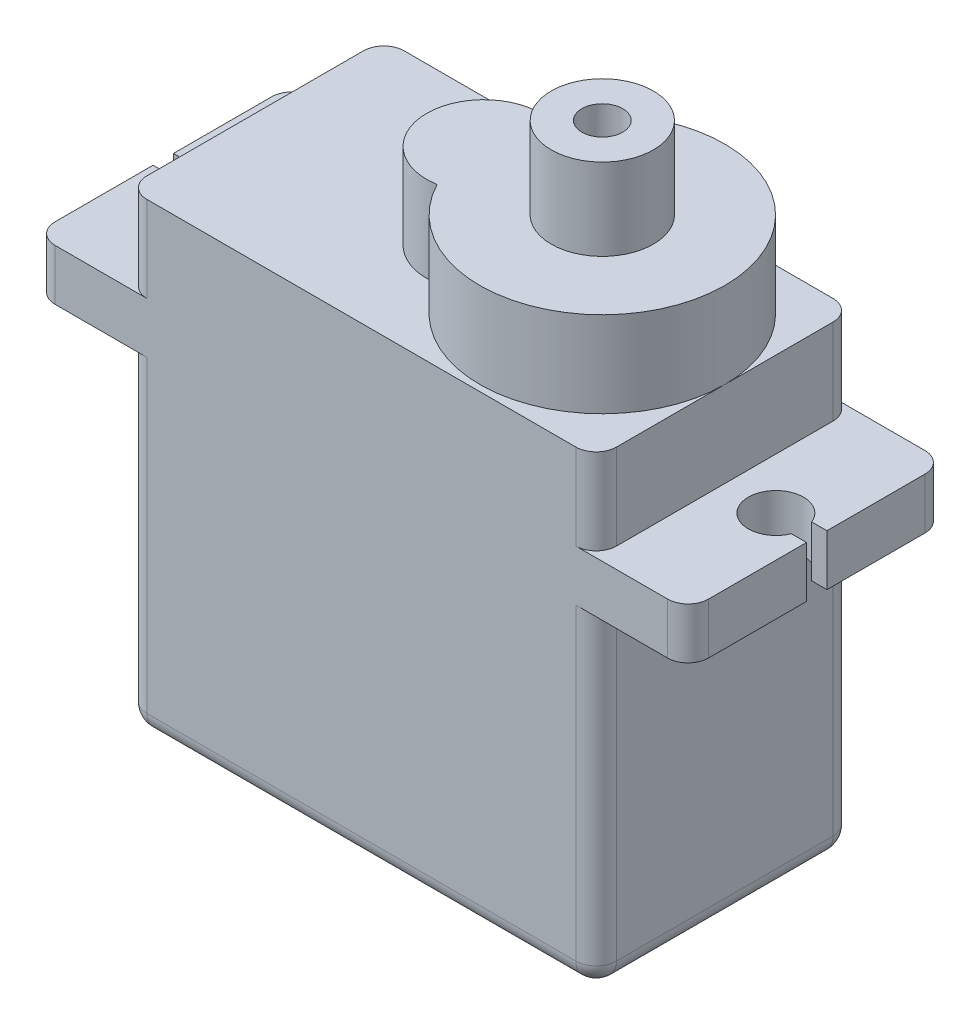
from build123d import *

# Parameters (mm, degrees)
SKETCH1_W            = 23
SKETCH1_H            = 12.6
BOSS_EXTRUDE1_DEPTH  = 22.8
BOSS_EXTRUDE2_DEPTH  = 4.2
SKETCH3_R            = 2.5
SKETCH3_R_2          = 1
EXTRUDE_THIN1_DEPTH  = 4
FILLET1_R            = 1
BOSS_EXTRUDE4_START  = -4.2
BOSS_EXTRUDE4_DEPTH  = 2.5
FILLET2_R            = 1
FILLET2_OF_MIRROR1_R = 1


with BuildPart() as part:
    # Sketch1 → Boss-Extrude1 (new body)
    with BuildSketch(Plane(origin=(0, 0, 0), x_dir=(1, 0, 0), z_dir=(0, 1, 0))):
        Rectangle(SKETCH1_W, SKETCH1_H)
    extrude(amount=BOSS_EXTRUDE1_DEPTH)

    # Sketch2 → Boss-Extrude2 (add)
    with BuildSketch(Plane(origin=(0, 22.8, 0), x_dir=(1, 0, 0), z_dir=(0, 1, 0))):
        with BuildLine():
            ThreePointArc((0.172413793, -2.759859636), (11.5, 0), (0.172413793, 2.759859636))
            ThreePointArc((0.172413793, 2.759859636), (-3.1, 0), (0.172413793, -2.759859636))
        make_face()
    extrude(amount=BOSS_EXTRUDE2_DEPTH)

    # Sketch3 → Extrude-Thin1 (add)
    with BuildSketch(Plane(origin=(0, 27, 0), x_dir=(1, 0, 0), z_dir=(0, 1, 0))):
        with Locations((5.5, 0)):
            Circle(SKETCH3_R)
        with Locations((5.5, 0)):
            Circle(SKETCH3_R_2, mode=Mode.SUBTRACT)
    extrude(amount=EXTRUDE_THIN1_DEPTH)

    # Fillet1
    fillet1_edges = [part.edges().sort_by_distance(p)[0] for p in [
        (0, 0, 6.3),
        (-11.5, 0, 0),
        (0, 0, -6.3),
        (11.5, 0, 0),
        (11.5, 11.4, 6.3),
        (-11.5, 11.4, 6.3),
        (-11.5, 11.4, -6.3),
        (11.5, 11.4, -6.3),
    ]]
    fillet(fillet1_edges, radius=FILLET1_R)

    # Sketch4 → Boss-Extrude4 (add)
    with BuildSketch(Plane(origin=(0, 22.8, 0), x_dir=(1, 0, 0), z_dir=(0, 1, 0)).offset(BOSS_EXTRUDE4_START)):
        with BuildLine():
            Line((-9.107735151, 6.3), (-16, 6.3))
            Line((-16, 6.3), (-16, 0.5))
            Line((-16, 0.5), (-15.25399362, 0.5))
            ThreePointArc((-15.25399362, 0.5), (-12.65, 0), (-15.25399362, -0.5))
            Line((-15.25399362, -0.5), (-16, -0.5))
            Line((-16, -0.5), (-16, -6.3))
            Line((-16, -6.3), (-9.107735151, -6.3))
            Line((-9.107735151, -6.3), (-9.107735151, 6.3))
        make_face()
    boss_extrude4 = extrude(amount=-BOSS_EXTRUDE4_DEPTH)

    # Fillet2
    fillet2_edges = [part.edges().sort_by_distance(p)[0] for p in [
        (-16, 17.35, -6.3),
        (-16, 17.35, 6.3),
    ]]
    fillet(fillet2_edges, radius=FILLET2_R)

    # Mirror1: Boss-Extrude4 across plane
    add(boss_extrude4.mirror(Plane(origin=(0, 0, 0), x_dir=(0, 0, 1), z_dir=(1, 0, 0))))

    # Fillet2 of Mirror1
    fillet2_of_mirror1_edges = [part.edges().sort_by_distance(p)[0] for p in [
        (16, 17.35, -6.3),
        (16, 17.35, 6.3),
    ]]
    fillet(fillet2_of_mirror1_edges, radius=FILLET2_OF_MIRROR1_R)


solid = part.part
